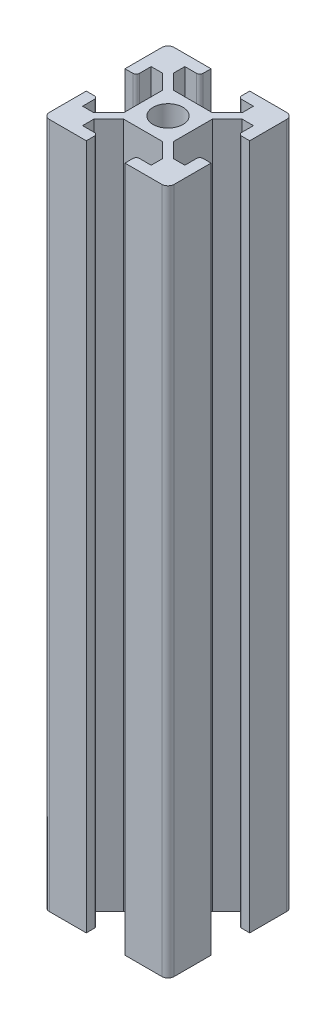
from build123d import *

# Parameters (mm, degrees)
SKETCH1_R           = 2.4
BOSS_EXTRUDE1_DEPTH = 110


with BuildPart() as part:
    # Sketch1 → Boss-Extrude1 (new body)
    with BuildSketch(Plane(origin=(0, 0, 0), x_dir=(1, 0, 0), z_dir=(0, 1, 0))):
        with BuildLine():
            ThreePointArc((-10, -9), (-9.707106781, -9.707106781), (-9, -10))
            Line((-9, -10), (-3.1, -10))
            Line((-3.1, -10), (-3.1, -8.7))
            ThreePointArc((-3.1, -8.7), (-3.246446609, -8.346446609), (-3.6, -8.2))
            Line((-3.6, -8.2), (-5.5, -8.2))
            Line((-5.5, -8.2), (-5.5, -6.376528763))
            Line((-5.5, -6.376528763), (-3.123471237, -4))
            Line((-3.123471237, -4), (0, -4))
            Line((0, -4), (3.123471237, -4))
            Line((3.123471237, -4), (5.5, -6.376528763))
            Line((5.5, -6.376528763), (5.5, -8.2))
            Line((5.5, -8.2), (3.6, -8.2))
            ThreePointArc((3.6, -8.2), (3.246446609, -8.346446609), (3.1, -8.7))
            Line((3.1, -8.7), (3.1, -10))
            Line((3.1, -10), (9, -10))
            ThreePointArc((9, -10), (9.707106781, -9.707106781), (10, -9))
            Line((10, -9), (10, -3.1))
            Line((10, -3.1), (8.7, -3.1))
            ThreePointArc((8.7, -3.1), (8.346446609, -3.246446609), (8.2, -3.6))
            Line((8.2, -3.6), (8.2, -5.5))
            Line((8.2, -5.5), (6.376528763, -5.5))
            Line((6.376528763, -5.5), (4, -3.123471237))
            Line((4, -3.123471237), (4, 0))
            Line((4, 0), (4, 3.123471237))
            Line((4, 3.123471237), (6.376528763, 5.5))
            Line((6.376528763, 5.5), (8.2, 5.5))
            Line((8.2, 5.5), (8.2, 3.6))
            ThreePointArc((8.2, 3.6), (8.346446609, 3.246446609), (8.7, 3.1))
            Line((8.7, 3.1), (10, 3.1))
            Line((10, 3.1), (10, 9))
            ThreePointArc((10, 9), (9.707106781, 9.707106781), (9, 10))
            Line((9, 10), (3.1, 10))
            Line((3.1, 10), (3.1, 8.7))
            ThreePointArc((3.1, 8.7), (3.246446609, 8.346446609), (3.6, 8.2))
            Line((3.6, 8.2), (5.5, 8.2))
            Line((5.5, 8.2), (5.5, 6.376528763))
            Line((5.5, 6.376528763), (3.123471237, 4))
            Line((3.123471237, 4), (0, 4))
            Line((0, 4), (-3.123471237, 4))
            Line((-3.123471237, 4), (-5.5, 6.376528763))
            Line((-5.5, 6.376528763), (-5.5, 8.2))
            Line((-5.5, 8.2), (-3.6, 8.2))
            ThreePointArc((-3.6, 8.2), (-3.246446609, 8.346446609), (-3.1, 8.7))
            Line((-3.1, 8.7), (-3.1, 10))
            Line((-3.1, 10), (-9, 10))
            ThreePointArc((-9, 10), (-9.707106781, 9.707106781), (-10, 9))
            Line((-10, 9), (-10, 3.1))
            Line((-10, 3.1), (-8.7, 3.1))
            ThreePointArc((-8.7, 3.1), (-8.346446609, 3.246446609), (-8.2, 3.6))
            Line((-8.2, 3.6), (-8.2, 5.5))
            Line((-8.2, 5.5), (-6.376528763, 5.5))
            Line((-6.376528763, 5.5), (-4, 3.123471237))
            Line((-4, 3.123471237), (-4, 0))
            Line((-4, 0), (-4, -3.123471237))
            Line((-4, -3.123471237), (-6.376528763, -5.5))
            Line((-6.376528763, -5.5), (-8.2, -5.5))
            Line((-8.2, -5.5), (-8.2, -3.6))
            ThreePointArc((-8.2, -3.6), (-8.346446609, -3.246446609), (-8.7, -3.1))
            Line((-8.7, -3.1), (-10, -3.1))
            Line((-10, -3.1), (-10, -9))
        make_face()
        Circle(SKETCH1_R, mode=Mode.SUBTRACT)
    extrude(amount=BOSS_EXTRUDE1_DEPTH)


solid = part.part
